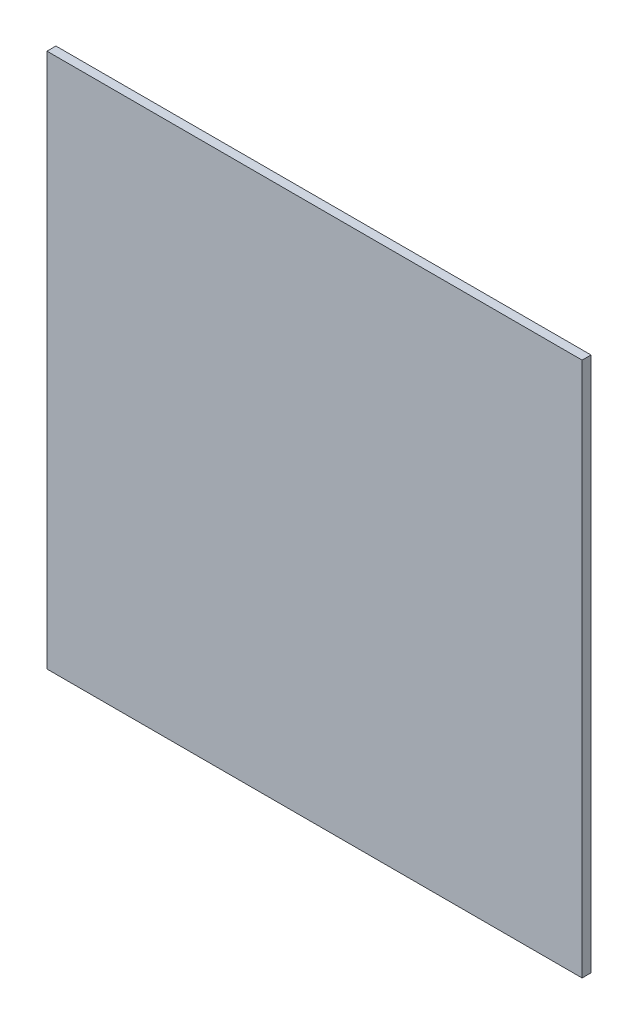
from build123d import *

# Parameters (mm, degrees)
SZKIC1_W                    = 300
SZKIC1_H                    = 300
DODANIE_WYCI_GNI_CIE1_DEPTH = 5


with BuildPart() as part:
    # Szkic1 → Dodanie-wyciągnięcie1 (new body)
    with BuildSketch(Plane.XY):
        with Locations((150, 150)):
            Rectangle(SZKIC1_W, SZKIC1_H)
    extrude(amount=DODANIE_WYCI_GNI_CIE1_DEPTH)


solid = part.part
